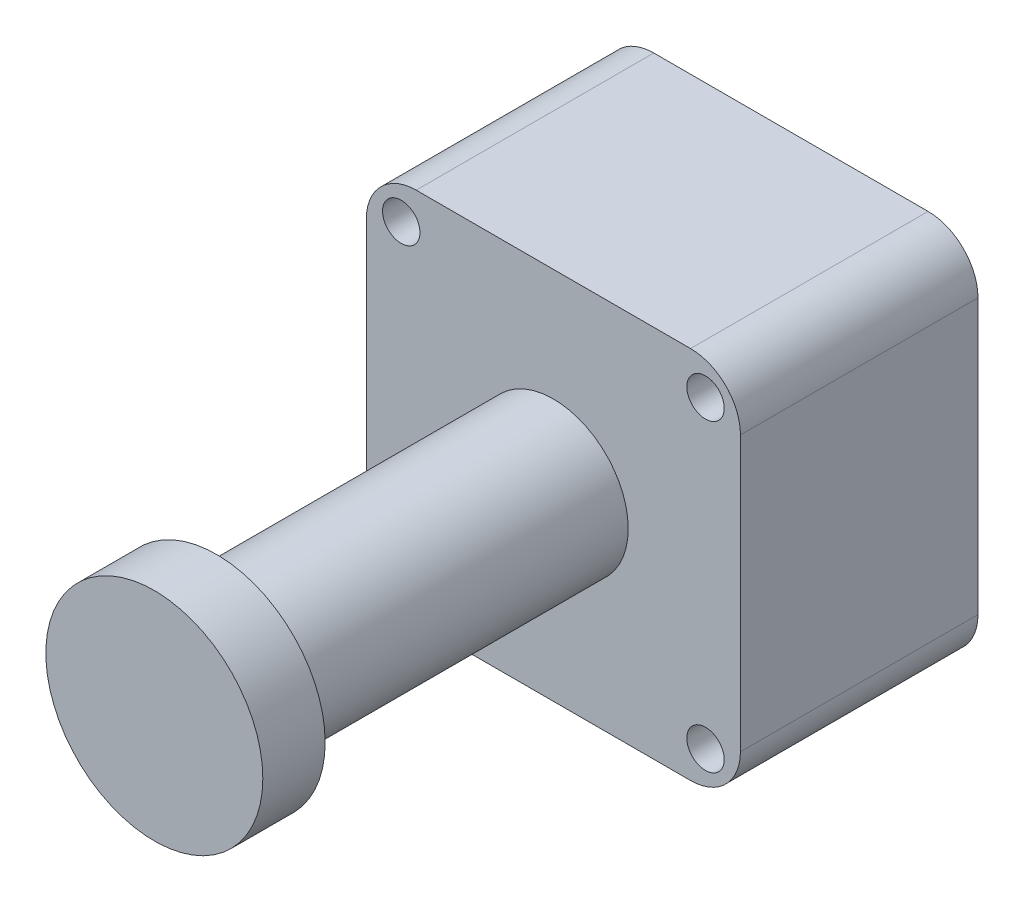
from build123d import *

# Parameters (mm, degrees)
SKETCH1_W           = 30
SKETCH1_H           = 30
BOSS_EXTRUDE1_DEPTH = 19.05
FILLET1_R           = 4
SKETCH2_R           = 1.5
CUT_EXTRUDE1_DEPTH  = 20.05
SKETCH3_R           = 8.7
BOSS_EXTRUDE2_DEPTH = 32
SKETCH4_R           = 8.7
SKETCH4_R_2         = 6
CUT_EXTRUDE2_DEPTH  = 27


with BuildPart() as part:
    # Sketch1 → Boss-Extrude1 (new body)
    with BuildSketch(Plane.XY):
        Rectangle(SKETCH1_W, SKETCH1_H)
    extrude(amount=BOSS_EXTRUDE1_DEPTH)

    # Fillet1
    fillet1_edges = [part.edges().sort_by_distance(p)[0] for p in [
        (15, -15, 9.525),
        (-15, -15, 9.525),
        (-15, 15, 9.525),
        (15, 15, 9.525),
    ]]
    fillet(fillet1_edges, radius=FILLET1_R)

    # Sketch2 → Cut-Extrude1 (cut, through all)
    with BuildSketch(Plane.XY.offset(19.05)):
        with Locations((-12.2, 12.2)):
            Circle(SKETCH2_R)
        with Locations((12.2, 12.2)):
            Circle(SKETCH2_R)
        with Locations((12.2, -12.2)):
            Circle(SKETCH2_R)
        with Locations((-12.2, -12.2)):
            Circle(SKETCH2_R)
    extrude(amount=-CUT_EXTRUDE1_DEPTH, mode=Mode.SUBTRACT)

    # Sketch3 → Boss-Extrude2 (add)
    with BuildSketch(Plane.XY.offset(19.05)):
        Circle(SKETCH3_R)
    extrude(amount=BOSS_EXTRUDE2_DEPTH)

    # Sketch4 → Cut-Extrude2 (cut)
    with BuildSketch(Plane.XY.offset(19.05)):
        Circle(SKETCH4_R)
        Circle(SKETCH4_R_2, mode=Mode.SUBTRACT)
    extrude(amount=CUT_EXTRUDE2_DEPTH, mode=Mode.SUBTRACT)


solid = part.part
